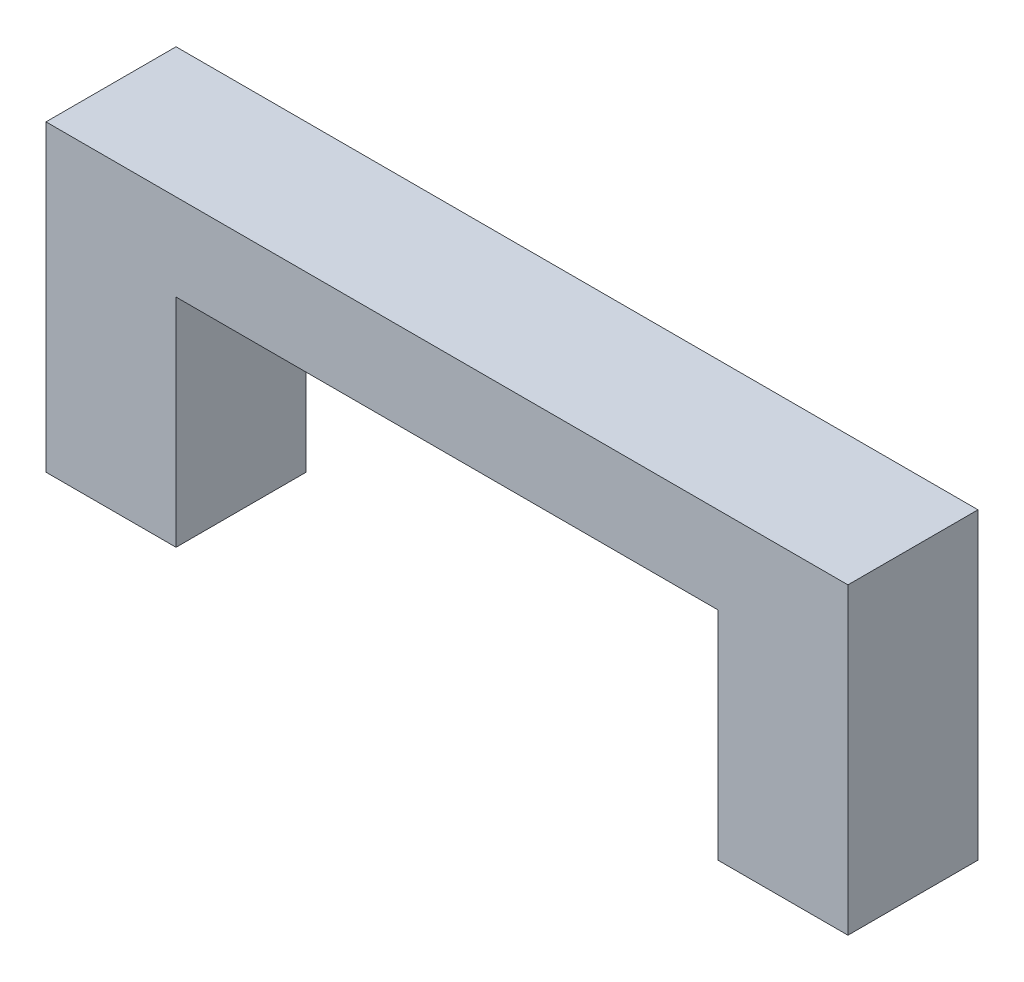
from build123d import *

# Parameters (mm, degrees)
BOSS_EXTRUDE1_DEPTH = 3
SKETCH2_W           = 1.5
SKETCH2_H           = 1.5
CUT_EXTRUDE1_DEPTH  = 2.2


with BuildPart() as part:
    # Sketch1 → Boss-Extrude1 (new body)
    with BuildSketch(Plane.XY):
        Polygon((0, 0), (0, 7), (18.5, 7), (18.5, 0), (15.5, 0), (15.5, 5), (3, 5), (3, 0), align=None)
    extrude(amount=BOSS_EXTRUDE1_DEPTH)

    # Sketch2 → Cut-Extrude1 (cut)
    with BuildSketch(Plane.XZ):
        with Locations((17, 1.5)):
            Rectangle(SKETCH2_W, SKETCH2_H)
        with Locations((1.5, 1.5)):
            Rectangle(SKETCH2_W, SKETCH2_H)
    extrude(amount=-CUT_EXTRUDE1_DEPTH, mode=Mode.SUBTRACT)


solid = part.part
